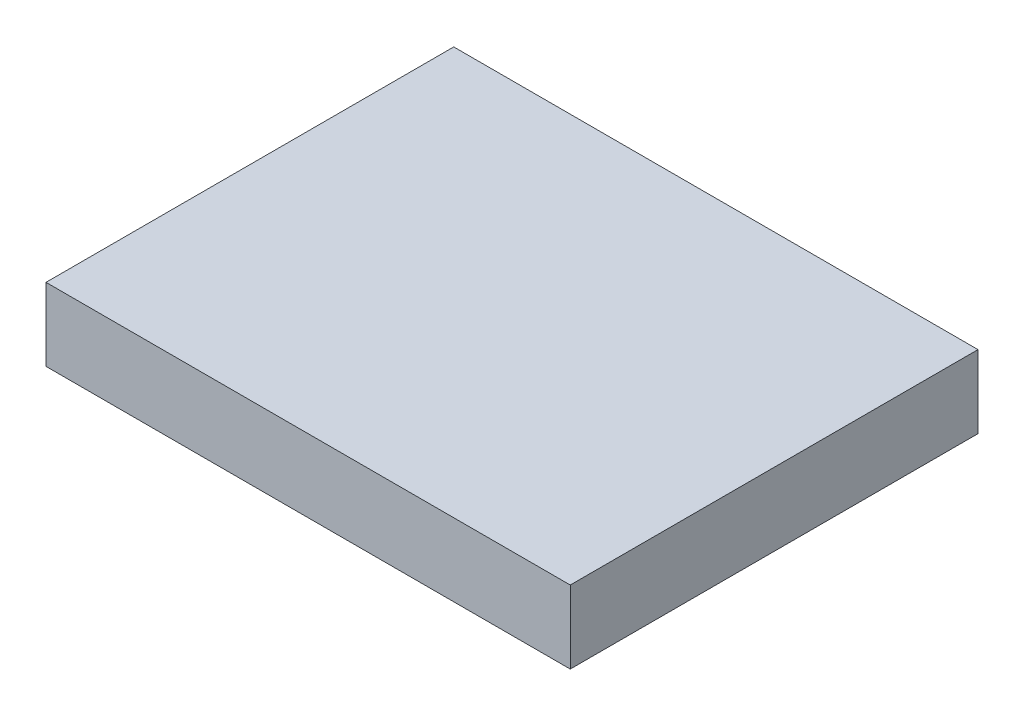
from build123d import *

# Parameters (mm, degrees)
SKETCH1_W           = 21.6
SKETCH1_H           = 16.8
BOSS_EXTRUDE1_DEPTH = 3


with BuildPart() as part:
    # Sketch1 → Boss-Extrude1 (new body)
    with BuildSketch(Plane(origin=(0, 0, 0), x_dir=(1, 0, 0), z_dir=(0, 1, 0))):
        with Locations((10.8, -8.4)):
            Rectangle(SKETCH1_W, SKETCH1_H)
    extrude(amount=BOSS_EXTRUDE1_DEPTH)


solid = part.part
